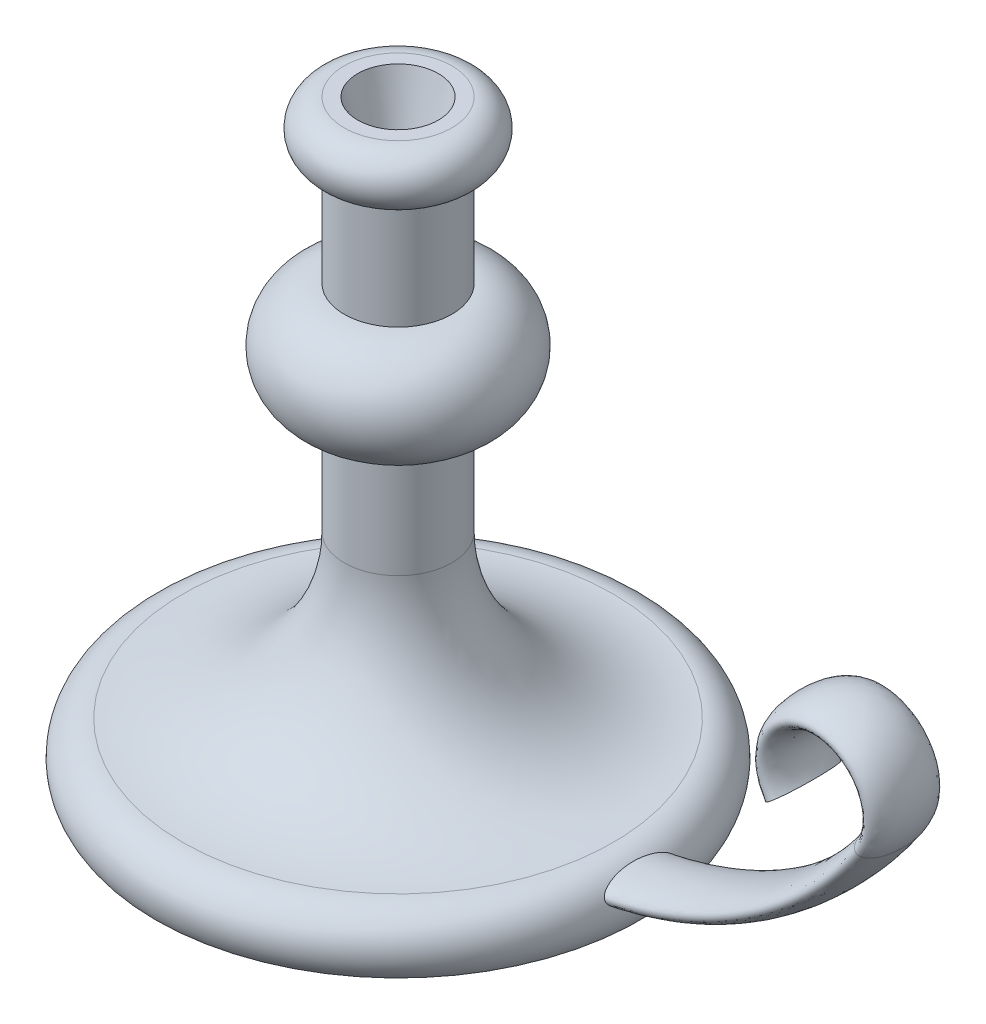
from build123d import *

# Parameters (mm, degrees)
SKETCH5_RX         = 13.333333333
SKETCH5_RY         = 5
SKETCH6_R          = 15
CUT_EXTRUDE1_DEPTH = 25
CUT_EXTRUDE1_TAPER = 15


with BuildPart() as part:
    # Sketch2 → Revolve1 (revolve)
    with BuildSketch(Plane.XY):
        with BuildLine():
            Line((0, 0), (0, 220))
            Line((0, 220), (20, 220))
            ThreePointArc((20, 220), (30, 210), (20, 200))
            Line((20, 200), (20, 160))
            ThreePointArc((20, 160), (40, 140), (20, 120))
            Line((20, 120), (20, 80))
            ThreePointArc((20, 80), (37.573593129, 37.573593129), (80, 20))
            ThreePointArc((80, 20), (91.180339887, 13.090169944), (90, 0))
            Line((90, 0), (0, 0))
        make_face()
    revolve(axis=Axis((0, 0, 0), (0, 1, 0)))

    # Sweep1: sweep along a path in Sketch3
    with BuildLine(Plane.XY) as sweep1_path:
        Line((0, 10), (60, 10))
        ThreePointArc((60, 10), (129.821200219, 27.240819526), (183.592070943, 75))
        ThreePointArc((183.592070943, 75), (167.113128151, 106.333333333), (150.634185358, 75))
    # Sketch5 → Sweep1 (sweep)
    with BuildSketch(Plane(origin=(0, 0, 0), x_dir=(0, 0, -1), z_dir=(1, 0, 0))):
        with Locations(Location((0, 10), (0, 0, 180))):
            Ellipse(SKETCH5_RX, SKETCH5_RY)
    sweep(path=sweep1_path.line)

    # Sketch6 → Cut-Extrude1 (cut)
    with BuildSketch(Plane(origin=(0, 220, 0), x_dir=(1, 0, 0), z_dir=(0, 1, 0))):
        Circle(SKETCH6_R)
    extrude(amount=-CUT_EXTRUDE1_DEPTH, taper=CUT_EXTRUDE1_TAPER, mode=Mode.SUBTRACT)


solid = part.part
